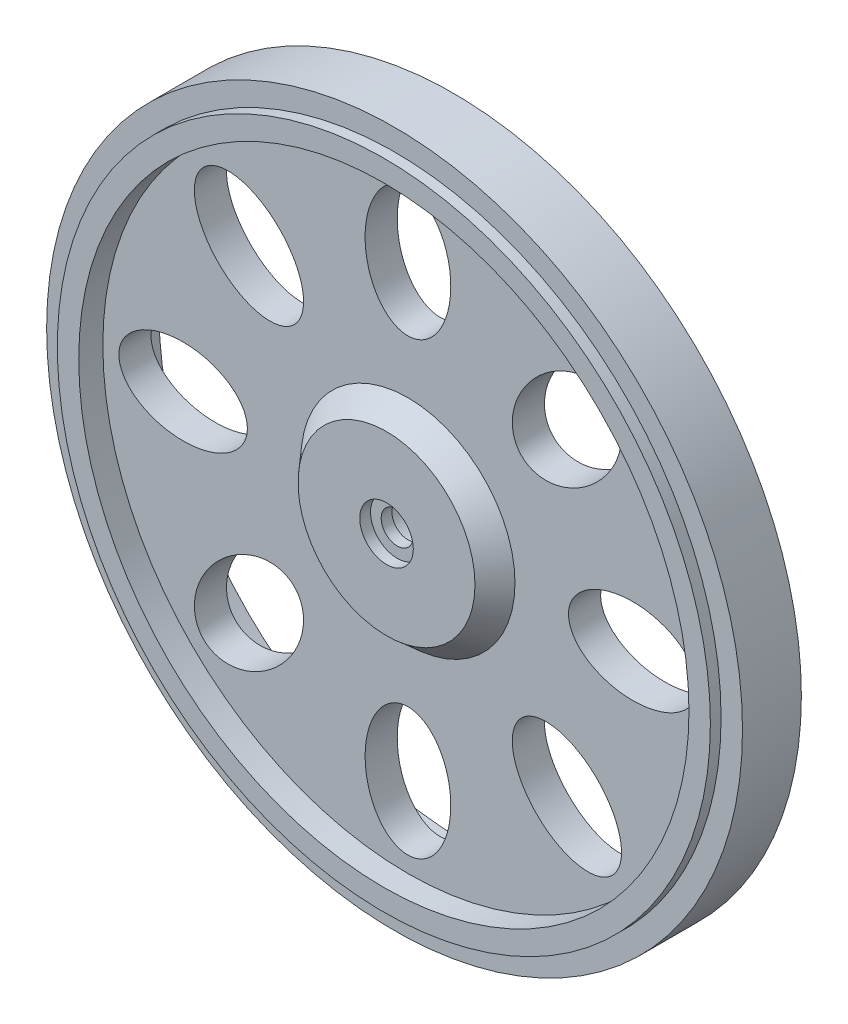
from build123d import *

# Parameters (mm, degrees)
SKETCH2_R           = 10
EXTRUDE1_DEPTH      = 2
EXTRUDE1_TAPER      = 41
SKETCH3_R           = 5.5
EXTRUDE2_DEPTH      = 4
EXTRUDE2_TAPER      = 15
SKETCH4_R           = 2.5
EXTRUDE3_DEPTH      = 1
SKETCH5_R           = 1.5
EXTRUDE4_DEPTH      = 24
EXTRUDE4_DEPTH_BACK = 15
SKETCH6_RX          = 6
SKETCH6_RY          = 4
EXTRUDE5_DEPTH      = 15
CIRPATTERN2_COUNT   = 8
SKETCH7_R           = 2.75
EXTRUDE6_DEPTH      = 7


with BuildPart() as part:
    # Sketch1 → Revolve1 (revolve)
    with BuildSketch(Plane(origin=(0, 0, 0), x_dir=(0, 0, -1), z_dir=(1, 0, 0))):
        Polygon((-3.75, 28.5), (-1.5, 28.5), (-1.5, 0), (1.5, 0), (1.5, 28.5), (3.75, 28.5), (3.75, 30.5), (2.75, 30.5), (2.75, 32.5), (-2.75, 32.5), (-2.75, 30.5), (-3.75, 30.5), align=None)
    revolve(axis=Axis((0, 0, 21.188406287), (0, 0, -1)))

    # Sketch2 → Extrude1 (add)
    with BuildSketch(Plane.XY.offset(1.5)):
        Circle(SKETCH2_R)
    extrude(amount=EXTRUDE1_DEPTH, taper=EXTRUDE1_TAPER)

    # Sketch3 → Extrude2 (add)
    with BuildSketch(Plane(origin=(0, 0, -1.5), x_dir=(-1, 0, 0), z_dir=(0, 0, -1))):
        Circle(SKETCH3_R)
    extrude(amount=EXTRUDE2_DEPTH, taper=EXTRUDE2_TAPER)

    # Sketch4 → Extrude3 (cut)
    with BuildSketch(Plane.XY.offset(3.5)):
        Circle(SKETCH4_R)
    extrude(amount=-EXTRUDE3_DEPTH, mode=Mode.SUBTRACT)

    # Sketch5 → Extrude4 (cut, two sides)
    with BuildSketch(Plane.XY.offset(2.5)) as extrude4_sk:
        Circle(SKETCH5_R)
    extrude(amount=EXTRUDE4_DEPTH, mode=Mode.SUBTRACT)
    extrude(extrude4_sk.sketch, amount=-EXTRUDE4_DEPTH_BACK, mode=Mode.SUBTRACT)

    # Sketch6 → Extrude5 (cut)
    with BuildSketch(Plane.XY.offset(1.5)):
        with Locations(Location((0, 21), (0, 0, 90))):
            Ellipse(SKETCH6_RX, SKETCH6_RY)
    extrude5 = extrude(amount=-EXTRUDE5_DEPTH, mode=Mode.SUBTRACT)

    # CirPattern2: Extrude5 ×8 about axis
    cirpattern2_axis = Axis((0, 0, 21.188406287), (0, 0, 1))
    for i in range(1, CIRPATTERN2_COUNT):
        add(extrude5.rotate(cirpattern2_axis, i * 360 / CIRPATTERN2_COUNT), mode=Mode.SUBTRACT)

    # Sketch7 → Extrude6 (cut)
    with BuildSketch(Plane(origin=(0, 0, -5.5), x_dir=(-1, 0, 0), z_dir=(0, 0, -1))):
        Circle(SKETCH7_R)
    extrude(amount=-EXTRUDE6_DEPTH, mode=Mode.SUBTRACT)


solid = part.part
